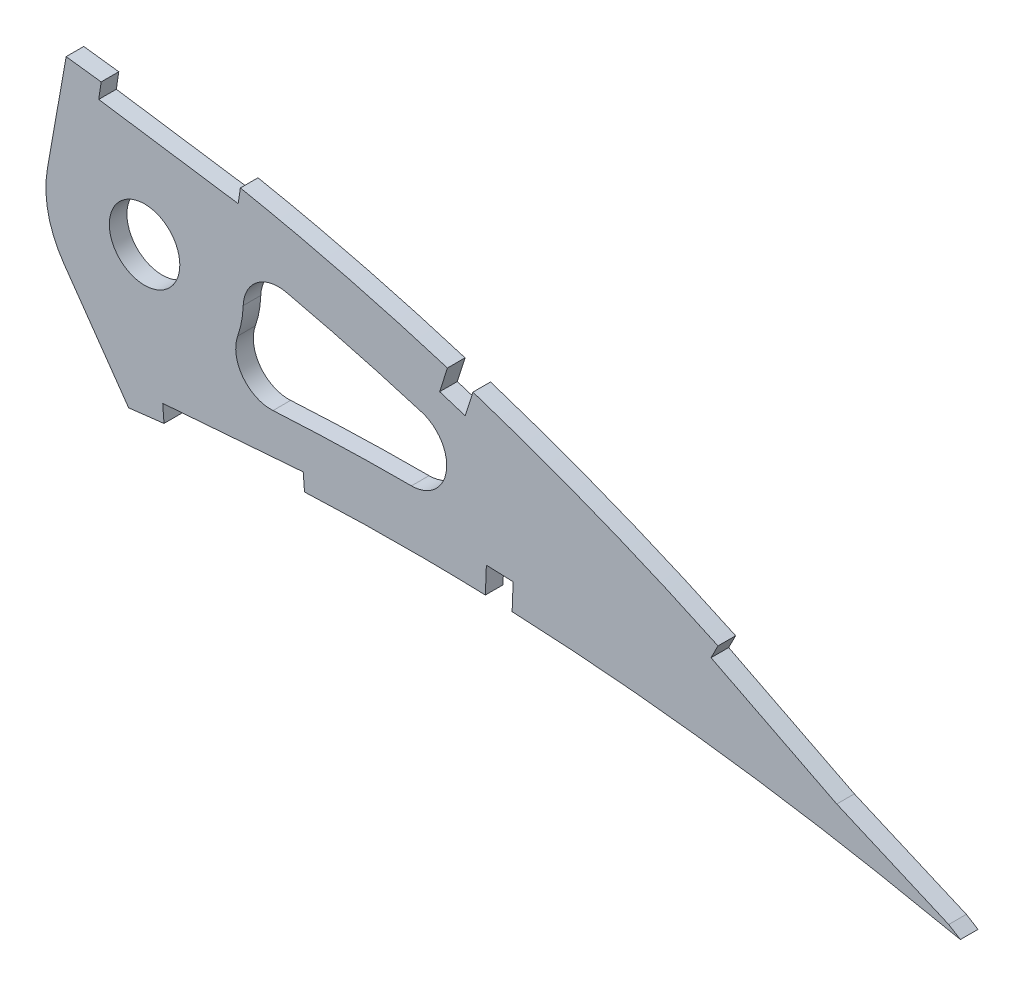
from build123d import *

# Parameters (mm, degrees)
BOSS_EXTRUDE1_DEPTH = 3.175
SKETCH4_R           = 6.35
CUT_EXTRUDE2_DEPTH  = 7.62
CUT_EXTRUDE3_DEPTH  = 7.62
FILLET1_R           = 6.35


with BuildPart() as part:
    # Sketch1 → Boss-Extrude1 (new body)
    with BuildSketch(Plane.XY):
        with BuildLine():
            Line((502.79773875, -0.784854231), (507.466663145, -1.71152324))
            Line((507.466663145, -1.71152324), (503.425622155, 0.784854231))
            add(Edge.make_bspline(
                [(503.425622155, 0.784854231), (503.387056523, 0.808678383), (503.232943706, 0.903882506), (502.885699565, 1.116877467), (502.307465731, 1.471631004), (501.497989026, 1.96567955), (500.45789772, 2.597710645), (499.186668738, 3.363298805), (497.685095824, 4.259956995), (495.953542232, 5.283444029), (493.992185329, 6.428967913), (491.80177187, 7.691887565), (489.382492784, 9.065053582), (486.735285081, 10.542854645), (483.861056965, 12.118262786), (480.760352067, 13.784162223), (477.434280878, 15.532079613), (473.88412009, 17.354496627), (470.110517029, 19.241349676), (466.11525081, 21.184786117), (461.8996524, 23.175115764), (457.465160771, 25.201720056), (452.814323541, 27.256337372), (447.948426531, 29.326194505), (442.870242622, 31.402323167), (437.581933839, 33.472908178), (432.086631293, 35.528519181), (426.386455038, 37.555839622), (420.485666169, 39.546009798), (414.38712726, 41.486101224), (408.095199476, 43.365577113), (401.613538504, 45.172251969), (394.947547526, 46.896860198), (388.101454206, 48.526842247), (381.081061063, 50.051288093), (373.891948514, 51.461019148), (366.540145776, 52.741961538), (359.04602551, 53.893116322), (351.530166329, 54.850682287), (344.029770472, 55.789835004), (336.540544467, 56.672083061), (328.959784459, 57.516957665), (321.294783559, 58.319701885), (313.553144836, 59.077805613), (305.74270558, 59.787996951), (297.871582303, 60.448193241), (289.947391455, 61.054653465), (281.978488624, 61.606443402), (273.972752071, 62.098711989), (265.938708914, 62.531089773), (257.884514812, 62.900561137), (249.818551509, 63.204580293), (241.749383842, 63.441312028), (233.685387885, 63.608488355), (225.6352949, 63.705058175), (217.607478242, 63.728382774), (209.610665097, 63.678044957), (201.65322943, 63.552316286), (193.743907339, 63.349475598), (185.891084219, 63.06914433), (178.103251674, 62.711444076), (170.388936599, 62.273379295), (162.75650763, 61.757741728), (155.21446412, 61.162365234), (147.771092618, 60.487091521), (140.434193858, 59.734735375), (133.21193631, 58.903250486), (126.112060053, 57.995002679), (119.142330926, 57.011772691), (112.310569153, 55.953024983), (105.624093076, 54.821817655), (99.090119317, 53.619308085), (92.715560781, 52.349021738), (86.507357689, 51.011289913), (80.472081741, 49.610125488), (74.616005172, 48.147969617), (68.945423127, 46.627499094), (63.466083945, 45.052362302), (58.183528407, 43.426132862), (53.103914735, 41.750597597), (48.231081995, 40.032109382), (43.57101596, 38.271888166), (39.127286386, 36.475356686), (34.905100975, 34.644967962), (30.907613889, 32.786301909), (27.139349344, 30.901474598), (23.602993011, 28.995766687), (20.302095112, 27.072100319), (17.239833127, 25.134048547), (14.417494091, 23.186527339), (11.838969232, 21.230759107), (9.505144331, 19.27168598), (7.417496279, 17.312291137), (5.579009223, 15.353924281), (3.9896169, 13.40003417), (2.651402342, 11.45216816), (1.564597701, 9.512169406), (0.731661122, 7.581447178), (0.1517667, 5.66108724), (-0.165663648, 3.753924021), (-0.244673978, 1.85842856), (-0.081436131, 0.618550581), (0, 0)],
                knots=[0, 0, 0, 0, 0.00025409, 0.001015373, 0.002283359, 0.004056577, 0.006330982, 0.009105275, 0.012374489, 0.016134023, 0.02037966, 0.025105976, 0.030306237, 0.035972206, 0.042099522, 0.048678064, 0.055701664, 0.063160184, 0.071045824, 0.079349826, 0.08806291, 0.097175757, 0.106678112, 0.116561573, 0.126814276, 0.1374283, 0.148393618, 0.15969976, 0.171338126, 0.183297699, 0.195569604, 0.208143556, 0.221011593, 0.234161831, 0.24758745, 0.261276822, 0.27522271, 0.289414144, 0.3037712, 0.317689227, 0.331784111, 0.346039677, 0.36044387, 0.374982721, 0.389640455, 0.404403317, 0.419256601, 0.434186749, 0.449177265, 0.464214782, 0.479284009, 0.49436974, 0.509457833, 0.524532346, 0.53957932, 0.554582984, 0.569529546, 0.584403417, 0.599190992, 0.613876838, 0.628447475, 0.642888675, 0.657186054, 0.671325546, 0.685294014, 0.699078147, 0.712665095, 0.726042645, 0.739197713, 0.752117586, 0.764792042, 0.777208152, 0.789355685, 0.80122396, 0.812803686, 0.824082909, 0.835054602, 0.845709571, 0.856037853, 0.866033834, 0.875688843, 0.884997719, 0.893953426, 0.902552897, 0.910789386, 0.918660734, 0.926166253, 0.933302626, 0.94007122, 0.94647478, 0.952517526, 0.958204819, 0.963546652, 0.9685566, 0.973249913, 0.977651041, 0.981787043, 0.985694226, 0.989415109, 0.993001157, 0.996508416, 1, 1, 1, 1], degree=3))
            add(Edge.make_bspline(
                [(0, 0), (0.129277918, -0.610277991), (0.388427893, -1.8336387), (1.09250455, -3.594771251), (2.023612315, -5.287729771), (3.201293003, -6.908017366), (4.61771618, -8.455191194), (6.269753486, -9.930860517), (8.155784822, -11.334231849), (10.273341647, -12.664666589), (12.619347944, -13.923576968), (15.191166787, -15.110180321), (17.986453192, -16.224105848), (21.002161638, -17.263864435), (24.234605302, -18.231039739), (27.680710983, -19.123274687), (31.336560086, -19.941816444), (35.198636392, -20.684575522), (39.262731423, -21.352306607), (43.524623173, -21.944635889), (47.97993709, -22.461933953), (52.624302184, -22.903115294), (57.453124717, -23.269128853), (62.461591735, -23.56021739), (67.644841608, -23.77730407), (72.997909324, -23.919563453), (78.51555217, -23.989213541), (84.19278374, -23.987299874), (90.024050352, -23.913310584), (96.004370725, -23.771333186), (102.128006069, -23.560468263), (108.38942798, -23.283267615), (114.782988575, -22.942520838), (121.302953529, -22.539383102), (127.943585047, -22.075641101), (134.699117226, -21.555013733), (141.563413308, -20.978799747), (148.530486699, -20.350357624), (155.594169408, -19.672833542), (162.748358534, -18.948371701), (169.986739237, -18.180380072), (177.302864412, -17.371347266), (184.690510287, -16.525589468), (192.142928282, -15.644636961), (199.653816553, -14.733519469), (207.21610926, -13.793977853), (214.823482798, -12.829630943), (222.469095066, -11.845019347), (230.145788458, -10.840030717), (237.847106351, -9.821825282), (245.565621831, -8.789564391), (253.29461644, -7.748557009), (261.026935583, -6.702038843), (268.755047845, -5.650332066), (276.472159998, -4.597795103), (284.171113039, -3.547317471), (291.844365725, -2.498995132), (299.484975802, -1.458038633), (307.085249349, -0.424320765), (314.63817827, 0.600062666), (322.136524598, 1.612053914), (329.5732141, 2.610375922), (336.940575301, 3.59439687), (344.231196069, 4.564486382), (351.328594574, 5.491199859), (358.214225209, 6.423884937), (364.911291302, 7.188480074), (371.524970385, 7.841089466), (378.062132498, 8.376139176), (384.514927939, 8.801326851), (390.8759632, 9.119690648), (397.137657243, 9.335675398), (403.292100638, 9.455688483), (409.331606334, 9.482775598), (415.247930621, 9.425574995), (421.03337879, 9.288697453), (426.679876255, 9.07828687), (432.179545635, 8.801442011), (437.52457516, 8.465709972), (442.70694032, 8.076042936), (447.719419769, 7.641538035), (452.554279933, 7.168555777), (457.204096822, 6.662500198), (461.662085653, 6.133975032), (465.921110964, 5.586460219), (469.974766574, 5.028953281), (473.816527145, 4.467104121), (477.440308359, 3.908085671), (480.840416637, 3.3572311), (484.011359843, 2.821851589), (486.948170814, 2.306949228), (489.645753402, 1.817552616), (492.100365244, 1.35983632), (494.307158383, 0.936074272), (496.26318146, 0.553249972), (497.964797452, 0.213052808), (499.40951194, -0.07972438), (500.594801875, -0.323926), (501.518867114, -0.515543372), (502.179882379, -0.654882666), (502.577132717, -0.73779659), (502.753636076, -0.775446656), (502.79773875, -0.784854231)],
                knots=[0, 0, 0, 0, 0.003638255, 0.007293231, 0.011028136, 0.014901081, 0.018963272, 0.023258475, 0.027820626, 0.032679082, 0.03785316, 0.043361875, 0.049214679, 0.055422346, 0.061988786, 0.068918036, 0.076211157, 0.083868392, 0.091887411, 0.100265912, 0.108999867, 0.118084529, 0.127514843, 0.13728527, 0.147387917, 0.157816481, 0.168563473, 0.179619128, 0.190977373, 0.202626974, 0.214560478, 0.226767249, 0.239236417, 0.251959004, 0.264923894, 0.278119703, 0.291536035, 0.30516028, 0.318980685, 0.332985499, 0.34716279, 0.361498603, 0.375980747, 0.390597192, 0.405332593, 0.420174823, 0.435109533, 0.450124276, 0.465203068, 0.480333154, 0.495500583, 0.510689775, 0.525887334, 0.541078314, 0.556247233, 0.571381784, 0.586466041, 0.601484516, 0.616424329, 0.631269422, 0.646006524, 0.660620684, 0.675098188, 0.689422858, 0.703581825, 0.716907564, 0.730009274, 0.742952128, 0.755725558, 0.768319952, 0.780724337, 0.792926529, 0.804916041, 0.816679084, 0.828203524, 0.8394749, 0.850481359, 0.861207697, 0.871639326, 0.881763414, 0.891563605, 0.901027364, 0.910138977, 0.918883976, 0.927249278, 0.935221104, 0.942784739, 0.949928188, 0.956638464, 0.962904203, 0.968712287, 0.974054485, 0.978918432, 0.983297219, 0.987180246, 0.990560674, 0.993433357, 0.995790625, 0.997629587, 0.998945816, 0.999736592, 1, 1, 1, 1], degree=3))
        make_face()
    extrude(amount=BOSS_EXTRUDE1_DEPTH)

    # Sketch4 → Cut-Extrude2 (cut)
    with BuildSketch(Plane.XY.offset(3.175)):
        with BuildLine():
            ThreePointArc((345.923037017, 23.034385848), (343.129017358, 29.38427855), (342.977678516, 36.320039485))
            Line((342.977678516, 36.320039485), (344.591947901, 45.475016103))
            add(Edge.make_bspline(
                [(344.591947901, 45.475016103), (342.217125187, 45.765583686), (337.119956997, 46.380169717), (326.504508092, 47.5759089), (307.286711362, 49.538634264), (279.771472095, 51.731982554), (246.717887367, 53.319528838), (213.664570119, 53.755236804), (180.669134648, 52.90135311), (147.815176918, 50.563224522), (120.662518003, 47.164608782), (99.187684825, 43.378733112), (83.258889286, 39.938157298), (67.57460437, 35.80637251), (54.804061967, 31.686853977), (44.878484905, 27.895857791), (37.627261577, 24.772757465), (30.64232008, 21.334576555), (24.043924477, 17.538231982), (18.044684245, 13.349298693), (13.89230662, 9.544644908), (11.520888391, 6.523296537), (10.574828241, 4.819667244), (10.154285067, 3.658804187), (10.029712376, 3.119509695), (9.96715768, 2.622534119), (9.957193428, 2.399818071), (9.958757578, 2.319108507), (9.960134, 2.282436718), (9.97553862, 2.108091793), (9.997964128, 1.911711392), (10.014224292, 1.780098795), (10.022028731, 1.718508468)],
                knots=[0.314347038, 0.314347038, 0.314347038, 0.314347038, 0.327852574, 0.343464601, 0.374688656, 0.437136765, 0.499584874, 0.562032984, 0.624481093, 0.686929202, 0.749377311, 0.780601366, 0.811825421, 0.843049475, 0.87427353, 0.889885557, 0.905497585, 0.921109612, 0.936721639, 0.952333667, 0.967945694, 0.975751708, 0.983557721, 0.987460728, 0.991363735, 0.993315238, 0.995266742, 0.996242494, 0.997218245, 0.998193997, 0.998681873, 0.999169749, 0.999169749, 0.999169749, 0.999169749], degree=3))
            add(Edge.make_bspline(
                [(10.022028731, 1.718508468), (10.034732545, 1.659934305), (10.062148332, 1.535306175), (10.10532172, 1.346851405), (10.148544363, 1.176384562), (10.163402463, 1.126864642), (10.184586308, 1.062344629), (10.258224332, 0.873920918), (10.471011291, 0.437774933), (10.758200301, -0.030655358), (11.474520662, -0.940450151), (12.834752912, -2.211708695), (15.846543126, -4.250621712), (20.730889178, -6.527621617), (27.42436325, -8.650889303), (34.567799193, -10.285570917), (41.969422132, -11.521391867), (49.531119997, -12.438619575), (59.752088408, -13.307746506), (72.702553512, -13.846429601), (88.379829234, -13.850370372), (104.132055949, -13.362967714), (125.191668888, -12.198456674), (151.574353295, -9.97888848), (183.265565017, -6.539398618), (214.980926495, -2.61000684), (246.712562055, 1.597085782), (278.475416723, 5.928250589), (304.961299825, 9.547136196), (323.521834022, 12.051492821), (334.125806317, 13.468813313), (340.757001517, 14.352789228), (346.075661613, 15.051379581), (349.047768348, 15.442398015), (350.709923825, 15.66427773), (351.051681205, 15.709922873)],
                knots=[0.000864765, 0.000864765, 0.000864765, 0.000864765, 0.001352624, 0.001840483, 0.002816201, 0.003791919, 0.004767637, 0.006719074, 0.00867051, 0.012573382, 0.016476254, 0.024281998, 0.032087742, 0.04769923, 0.063310718, 0.078922206, 0.094533694, 0.110145182, 0.12575667, 0.156979646, 0.188202622, 0.219425598, 0.250648574, 0.313094526, 0.375540478, 0.437986431, 0.500432383, 0.562878335, 0.625324287, 0.656547263, 0.672158751, 0.687770239, 0.695575983, 0.703381727, 0.705397928, 0.705397928, 0.705397928, 0.705397928], degree=3))
            Line((351.051681205, 15.709922873), (345.923037017, 23.034385848))
        make_face()
        with Locations((360.487560364, 33.232574886)):
            Circle(SKETCH4_R)
        with BuildLine():
            add(Edge.make_bspline(
                [(344.591947901, 45.475016103), (342.217125187, 45.765583686), (337.119956997, 46.380169717), (326.504508092, 47.5759089), (307.286711362, 49.538634264), (279.771472095, 51.731982554), (246.717887367, 53.319528838), (213.664570119, 53.755236804), (180.669134648, 52.90135311), (147.815176918, 50.563224522), (120.662518003, 47.164608782), (99.187684825, 43.378733112), (83.258889286, 39.938157298), (67.57460437, 35.80637251), (54.804061967, 31.686853977), (44.878484905, 27.895857791), (37.627261577, 24.772757465), (30.64232008, 21.334576555), (24.043924477, 17.538231982), (18.044684245, 13.349298693), (13.89230662, 9.544644908), (11.520888391, 6.523296537), (10.574828241, 4.819667244), (10.154285067, 3.658804187), (10.029712376, 3.119509695), (9.96715768, 2.622534119), (9.957193428, 2.399818071), (9.958757578, 2.319108507), (9.960134, 2.282436718), (9.97553862, 2.108091793), (9.997964128, 1.911711392), (10.014224292, 1.780098795), (10.022028731, 1.718508468)],
                knots=[0.314347038, 0.314347038, 0.314347038, 0.314347038, 0.327852574, 0.343464601, 0.374688656, 0.437136765, 0.499584874, 0.562032984, 0.624481093, 0.686929202, 0.749377311, 0.780601366, 0.811825421, 0.843049475, 0.87427353, 0.889885557, 0.905497585, 0.921109612, 0.936721639, 0.952333667, 0.967945694, 0.975751708, 0.983557721, 0.987460728, 0.991363735, 0.993315238, 0.995266742, 0.996242494, 0.997218245, 0.998193997, 0.998681873, 0.999169749, 0.999169749, 0.999169749, 0.999169749], degree=3))
            Line((344.591947901, 45.475016103), (346.35876981, 55.495161072))
            add(Edge.make_bspline(
                [(346.35876981, 55.495161072), (345.592592424, 55.589836283), (342.330459329, 55.990017767), (336.540544467, 56.672083061), (328.959784459, 57.516957665), (321.294783559, 58.319701885), (313.553144836, 59.077805613), (305.74270558, 59.787996951), (297.871582303, 60.448193241), (289.947391455, 61.054653465), (281.978488624, 61.606443402), (273.972752071, 62.098711989), (265.938708914, 62.531089773), (257.884514812, 62.900561137), (249.818551509, 63.204580293), (241.749383842, 63.441312028), (233.685387885, 63.608488355), (225.6352949, 63.705058175), (217.607478242, 63.728382774), (209.610665097, 63.678044957), (201.65322943, 63.552316286), (193.743907339, 63.349475598), (185.891084219, 63.06914433), (178.103251674, 62.711444076), (170.388936599, 62.273379295), (162.75650763, 61.757741728), (155.21446412, 61.162365234), (147.771092618, 60.487091521), (140.434193858, 59.734735375), (133.21193631, 58.903250486), (126.112060053, 57.995002679), (119.142330926, 57.011772691), (112.310569153, 55.953024983), (105.624093076, 54.821817655), (99.090119317, 53.619308085), (92.715560781, 52.349021738), (86.507357689, 51.011289913), (80.472081741, 49.610125488), (74.616005172, 48.147969617), (68.945423127, 46.627499094), (63.466083945, 45.052362302), (58.183528407, 43.426132862), (53.103914735, 41.750597597), (48.231081995, 40.032109382), (43.57101596, 38.271888166), (39.127286386, 36.475356686), (34.905100975, 34.644967962), (30.907613889, 32.786301909), (27.139349344, 30.901474598), (23.602993011, 28.995766687), (20.302095112, 27.072100319), (17.239833127, 25.134048547), (14.417494091, 23.186527339), (11.838969232, 21.230759107), (9.505144331, 19.27168598), (7.417496279, 17.312291137), (5.579009223, 15.353924281), (3.9896169, 13.40003417), (2.651402342, 11.45216816), (1.564597701, 9.512169406), (0.731661122, 7.581447178), (0.1517667, 5.66108724), (-0.165663648, 3.753924021), (-0.244673978, 1.85842856), (-0.081436131, 0.618550581), (0, 0)],
                knots=[0.31336195, 0.31336195, 0.31336195, 0.31336195, 0.317689227, 0.331784111, 0.346039677, 0.36044387, 0.374982721, 0.389640455, 0.404403317, 0.419256601, 0.434186749, 0.449177265, 0.464214782, 0.479284009, 0.49436974, 0.509457833, 0.524532346, 0.53957932, 0.554582984, 0.569529546, 0.584403417, 0.599190992, 0.613876838, 0.628447475, 0.642888675, 0.657186054, 0.671325546, 0.685294014, 0.699078147, 0.712665095, 0.726042645, 0.739197713, 0.752117586, 0.764792042, 0.777208152, 0.789355685, 0.80122396, 0.812803686, 0.824082909, 0.835054602, 0.845709571, 0.856037853, 0.866033834, 0.875688843, 0.884997719, 0.893953426, 0.902552897, 0.910789386, 0.918660734, 0.926166253, 0.933302626, 0.94007122, 0.94647478, 0.952517526, 0.958204819, 0.963546652, 0.9685566, 0.973249913, 0.977651041, 0.981787043, 0.985694226, 0.989415109, 0.993001157, 0.996508416, 1, 1, 1, 1], degree=3))
            add(Edge.make_bspline(
                [(0, 0), (0.129277918, -0.610277991), (0.388427893, -1.8336387), (1.09250455, -3.594771251), (2.023612315, -5.287729771), (3.201293003, -6.908017366), (4.61771618, -8.455191194), (6.269753486, -9.930860517), (8.155784822, -11.334231849), (10.273341647, -12.664666589), (12.619347944, -13.923576968), (15.191166787, -15.110180321), (17.986453192, -16.224105848), (21.002161638, -17.263864435), (24.234605302, -18.231039739), (27.680710983, -19.123274687), (31.336560086, -19.941816444), (35.198636392, -20.684575522), (39.262731423, -21.352306607), (43.524623173, -21.944635889), (47.97993709, -22.461933953), (52.624302184, -22.903115294), (57.453124717, -23.269128853), (62.461591735, -23.56021739), (67.644841608, -23.77730407), (72.997909324, -23.919563453), (78.51555217, -23.989213541), (84.19278374, -23.987299874), (90.024050352, -23.913310584), (96.004370725, -23.771333186), (102.128006069, -23.560468263), (108.38942798, -23.283267615), (114.782988575, -22.942520838), (121.302953529, -22.539383102), (127.943585047, -22.075641101), (134.699117226, -21.555013733), (141.563413308, -20.978799747), (148.530486699, -20.350357624), (155.594169408, -19.672833542), (162.748358534, -18.948371701), (169.986739237, -18.180380072), (177.302864412, -17.371347266), (184.690510287, -16.525589468), (192.142928282, -15.644636961), (199.653816553, -14.733519469), (207.21610926, -13.793977853), (214.823482798, -12.829630943), (222.469095066, -11.845019347), (230.145788458, -10.840030717), (237.847106351, -9.821825282), (245.565621831, -8.789564391), (253.29461644, -7.748557009), (261.026935583, -6.702038843), (268.755047845, -5.650332066), (276.472159998, -4.597795103), (284.171113039, -3.547317471), (291.844365725, -2.498995132), (299.484975802, -1.458038633), (307.085249349, -0.424320765), (314.63817827, 0.600062666), (322.136524598, 1.612053914), (329.5732141, 2.610375922), (336.940575301, 3.59439687), (344.231196069, 4.564486382), (351.117851665, 5.463682975), (355.570236242, 6.065792972), (357.622644751, 6.325614382)],
                knots=[0, 0, 0, 0, 0.003638255, 0.007293231, 0.011028136, 0.014901081, 0.018963272, 0.023258475, 0.027820626, 0.032679082, 0.03785316, 0.043361875, 0.049214679, 0.055422346, 0.061988786, 0.068918036, 0.076211157, 0.083868392, 0.091887411, 0.100265912, 0.108999867, 0.118084529, 0.127514843, 0.13728527, 0.147387917, 0.157816481, 0.168563473, 0.179619128, 0.190977373, 0.202626974, 0.214560478, 0.226767249, 0.239236417, 0.251959004, 0.264923894, 0.278119703, 0.291536035, 0.30516028, 0.318980685, 0.332985499, 0.34716279, 0.361498603, 0.375980747, 0.390597192, 0.405332593, 0.420174823, 0.435109533, 0.450124276, 0.465203068, 0.480333154, 0.495500583, 0.510689775, 0.525887334, 0.541078314, 0.556247233, 0.571381784, 0.586466041, 0.601484516, 0.616424329, 0.631269422, 0.646006524, 0.660620684, 0.675098188, 0.689422858, 0.703581825, 0.715666119, 0.715666119, 0.715666119, 0.715666119], degree=3))
            Line((357.622644751, 6.325614382), (351.051681205, 15.709922873))
            add(Edge.make_bspline(
                [(10.022028731, 1.718508468), (10.034732545, 1.659934305), (10.062148332, 1.535306175), (10.10532172, 1.346851405), (10.148544363, 1.176384562), (10.163402463, 1.126864642), (10.184586308, 1.062344629), (10.258224332, 0.873920918), (10.471011291, 0.437774933), (10.758200301, -0.030655358), (11.474520662, -0.940450151), (12.834752912, -2.211708695), (15.846543126, -4.250621712), (20.730889178, -6.527621617), (27.42436325, -8.650889303), (34.567799193, -10.285570917), (41.969422132, -11.521391867), (49.531119997, -12.438619575), (59.752088408, -13.307746506), (72.702553512, -13.846429601), (88.379829234, -13.850370372), (104.132055949, -13.362967714), (125.191668888, -12.198456674), (151.574353295, -9.97888848), (183.265565017, -6.539398618), (214.980926495, -2.61000684), (246.712562055, 1.597085782), (278.475416723, 5.928250589), (304.961299825, 9.547136196), (323.521834022, 12.051492821), (334.125806317, 13.468813313), (340.757001517, 14.352789228), (346.075661613, 15.051379581), (349.047768348, 15.442398015), (350.709923825, 15.66427773), (351.051681205, 15.709922873)],
                knots=[0.000864765, 0.000864765, 0.000864765, 0.000864765, 0.001352624, 0.001840483, 0.002816201, 0.003791919, 0.004767637, 0.006719074, 0.00867051, 0.012573382, 0.016476254, 0.024281998, 0.032087742, 0.04769923, 0.063310718, 0.078922206, 0.094533694, 0.110145182, 0.12575667, 0.156979646, 0.188202622, 0.219425598, 0.250648574, 0.313094526, 0.375540478, 0.437986431, 0.500432383, 0.562878335, 0.625324287, 0.656547263, 0.672158751, 0.687770239, 0.695575983, 0.703381727, 0.705397928, 0.705397928, 0.705397928, 0.705397928], degree=3))
        make_face()
        with BuildLine():
            add(Edge.make_bspline(
                [(449.310029247, 17.688169663), (446.249039459, 19.020747171), (433.170756117, 24.506393863), (414.679058579, 31.031047018), (393.80463939, 36.815465198), (382.827401771, 39.31649937), (377.108884499, 40.466906028), (376.692008323, 40.549969666)],
                knots=[0.10567262, 0.10567262, 0.10567262, 0.10567262, 0.124896219, 0.187344328, 0.218568383, 0.249792437, 0.252246711, 0.252246711, 0.252246711, 0.252246711], degree=3))
            ThreePointArc((376.692008323, 40.549969666), (377.869209951, 36.975121833), (378.267560364, 33.232574886))
            ThreePointArc((378.267560364, 33.232574886), (375.881434835, 24.335551295), (369.363507634, 17.826538404))
            add(Edge.make_bspline(
                [(369.363507634, 17.826538404), (371.058927837, 17.984695414), (378.219642958, 18.60897736), (390.853329275, 19.378611039), (412.76643338, 19.853777151), (432.270770063, 19.143728063), (446.241905154, 17.975888205), (449.310029247, 17.688169663)],
                knots=[0.740513727, 0.740513727, 0.740513727, 0.740513727, 0.750216191, 0.781439167, 0.812662144, 0.875108096, 0.892707, 0.892707, 0.892707, 0.892707], degree=3))
        make_face()
    extrude(amount=-CUT_EXTRUDE2_DEPTH, mode=Mode.SUBTRACT)

    # Sketch5 → Cut-Extrude3 (cut)
    with BuildSketch(Plane.XY.offset(3.175)):
        Polygon((352.692050817, 54.890502964), (352.229394909, 51.749768196), (377.355273059, 48.048520932), (377.817928967, 51.1892557), align=None)
        Polygon((415.116140728, 41.458988723), (413.656945017, 36.860339024), (418.255594716, 35.401143313), (419.714790427, 39.999793012), align=None)
        Polygon((422.066041652, 14.009863458), (421.884586072, 9.188482963), (426.705966568, 9.007027383), (426.887422147, 13.828407878), align=None)
        Polygon((463.982164764, 22.630058453), (462.544778481, 19.79911738), (485.192307068, 8.300027116), (508.51024515, -1.771297252), (509.769160696, 1.143445009), (486.541107392, 11.175946957), align=None)
        Polygon((389.071727807, 12.053529198), (363.754487196, 10.095553464), (363.999234163, 6.930898388), (389.316474773, 8.888874122), align=None)
    extrude(amount=-CUT_EXTRUDE3_DEPTH, mode=Mode.SUBTRACT)

    # Fillet1
    fillet1_edges = [part.edges().sort_by_distance(p)[0] for p in [
        (449.310029247, 17.688169663, 1.5875),
        (369.363507634, 17.826538404, 1.5875),
        (376.692008323, 40.549969666, 1.5875),
    ]]
    fillet(fillet1_edges, radius=FILLET1_R)


solid = part.part
